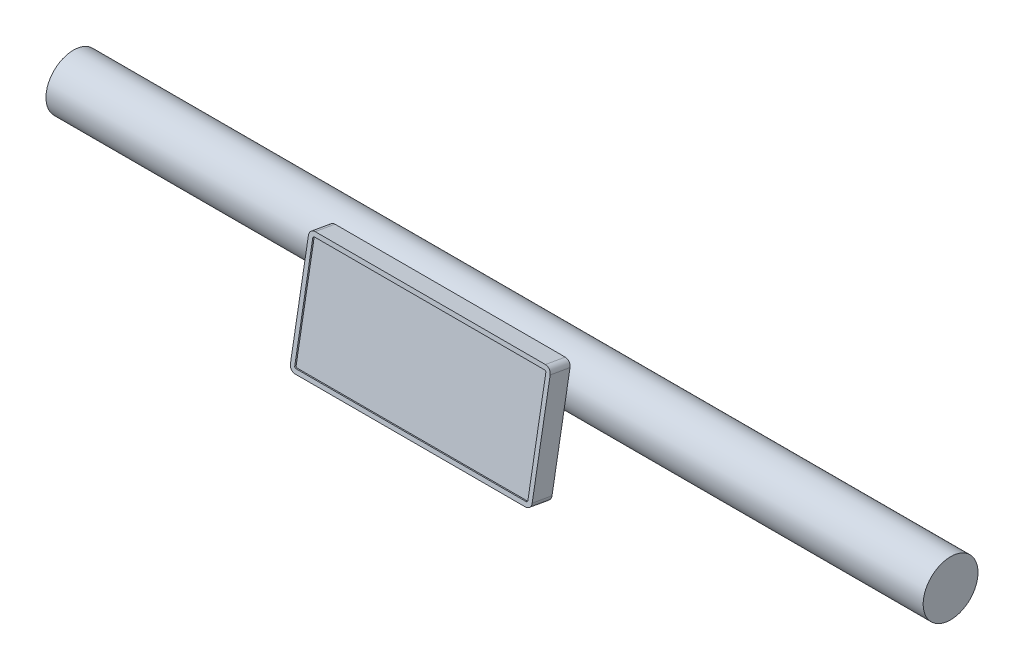
from build123d import *

# Parameters (mm, degrees)
SKETCH1_R           = 19.05
BOSS_EXTRUDE1_DEPTH = 304.8
SKETCH7_W           = 168
SKETCH7_H           = 80
BOSS_EXTRUDE3_DEPTH = 14
BOSS_EXTRUDE4_REACH = 76.765
SKETCH8_R           = 8.269516538
FILLET1_R           = 4
CUT_EXTRUDE2_DEPTH  = 1


with BuildPart() as part:
    # Sketch1 → Boss-Extrude1 (new body, symmetric)
    with BuildSketch(Plane(origin=(0, 0, 0), x_dir=(0, 0, -1), z_dir=(1, 0, 0))):
        Circle(SKETCH1_R)
    extrude(amount=BOSS_EXTRUDE1_DEPTH, both=True)


with BuildPart() as body_2:
    # Sketch7 → Boss-Extrude3 (new body)
    with BuildSketch(Plane(origin=(0, 11.233801501, 63.710054219), x_dir=(1, 0, 0), z_dir=(0, 0.173648178, 0.984807753))):
        Rectangle(SKETCH7_W, SKETCH7_H)
    extrude(amount=-BOSS_EXTRUDE3_DEPTH)

    # Fillet1
    fillet1_edges = [body_2.edges().sort_by_distance(p)[0] for p in [
        (84, -29.374045863, 63.762327055),
        (-84, -29.374045863, 63.762327055),
        (-84, 49.410574378, 49.870472841),
        (84, 49.410574378, 49.870472841),
    ]]
    fillet(fillet1_edges, radius=FILLET1_R)

    # Sketch9 → Cut-Extrude2 (cut)
    with BuildSketch(Plane(origin=(0, 11.233801501, 63.710054219), x_dir=(1, 0, 0), z_dir=(0, 0.173648178, 0.984807753))):
        with BuildLine():
            Line((-80, -37), (80, -37))
            ThreePointArc((80, -37), (80.707106781, -36.707106781), (81, -36))
            Line((81, -36), (81, 36))
            ThreePointArc((81, 36), (80.707106781, 36.707106781), (80, 37))
            Line((80, 37), (-80, 37))
            ThreePointArc((-80, 37), (-80.707106781, 36.707106781), (-81, 36))
            Line((-81, 36), (-81, -36))
            ThreePointArc((-81, -36), (-80.707106781, -36.707106781), (-80, -37))
        make_face()
    extrude(amount=-CUT_EXTRUDE2_DEPTH, mode=Mode.SUBTRACT)


with BuildPart() as body_3:

    # Sketch8 → Boss-Extrude4 (new body, up to next)
    with BuildSketch(Plane(origin=(0, 8.802727014, 49.922745677), x_dir=(1, 0, 0), z_dir=(0, 0.173648178, 0.984807753)), mode=Mode.PRIVATE) as boss_extrude4_sk1:
        Circle(SKETCH8_R)
    boss_extrude4_tool1 = extrude(boss_extrude4_sk1.sketch, amount=-BOSS_EXTRUDE4_REACH, mode=Mode.PRIVATE) - part.part
    add(boss_extrude4_tool1.solids().sort_by_distance((0, 8.802727, 49.922746))[0])


solid = Compound([part.part, body_2.part, body_3.part])
